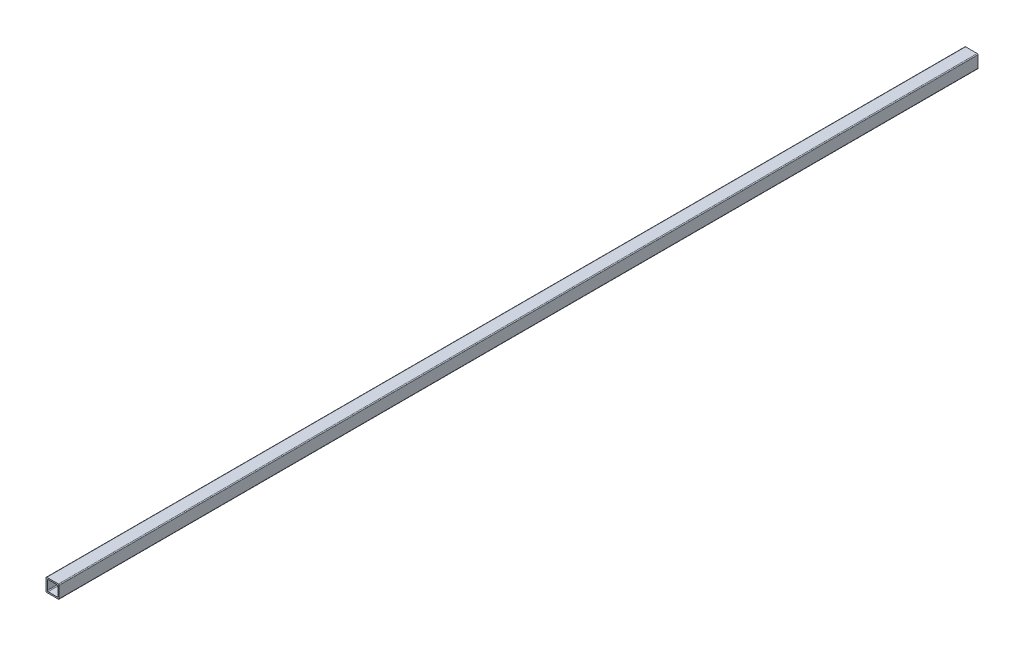
from build123d import *

# Parameters (mm, degrees)
SKETCH1_W           = 7.9
SKETCH1_H           = 7.9
SKETCH1_W_2         = 6.3
SKETCH1_H_2         = 6.3
BOSS_EXTRUDE1_DEPTH = 275
FILLET1_R           = 0.5


with BuildPart() as part:
    # Sketch1 → Boss-Extrude1 (new body, symmetric)
    with BuildSketch(Plane.XY):
        Rectangle(SKETCH1_W, SKETCH1_H)
        Rectangle(SKETCH1_W_2, SKETCH1_H_2, mode=Mode.SUBTRACT)
    extrude(amount=BOSS_EXTRUDE1_DEPTH, both=True)

    # Fillet1
    fillet1_edges = [part.edges().sort_by_distance(p)[0] for p in [
        (3.15, -3.15, 0),
        (3.15, 3.15, 0),
        (-3.15, 3.15, 0),
        (-3.15, -3.15, 0),
        (3.95, -3.95, 0),
        (-3.95, -3.95, 0),
        (-3.95, 3.95, 0),
        (3.95, 3.95, 0),
    ]]
    fillet(fillet1_edges, radius=FILLET1_R)


solid = part.part
